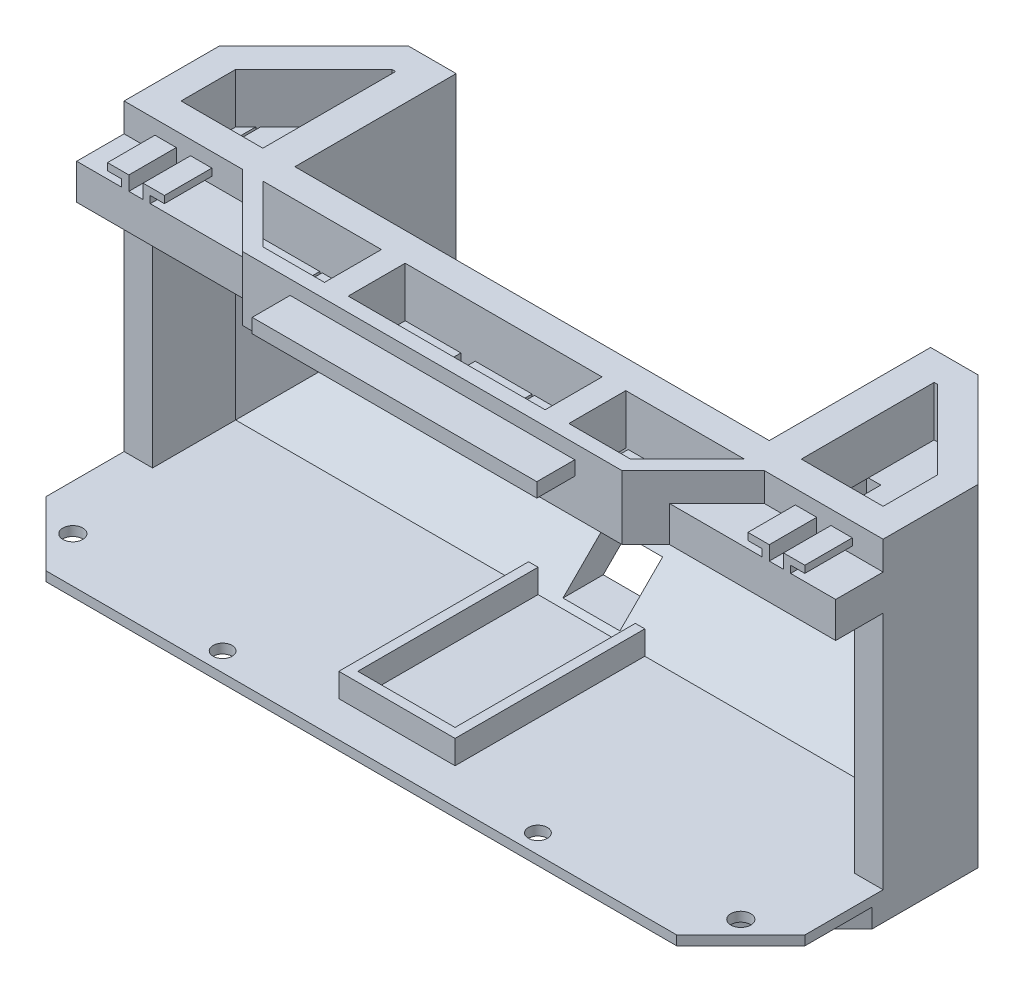
from build123d import *

# Parameters (mm, degrees)
BOSS_EXTRUDE1_DEPTH     = 70
CUT_EXTRUDE1_DEPTH      = 78.462449275
CUT_EXTRUDE1_DEPTH_BACK = 83.537550725
SHELL1_T                = -6
BOSS_EXTRUDE2_DEPTH     = 6
BOSS_EXTRUDE3_DEPTH     = 2
CUT_EXTRUDE5_REACH      = 68
SKETCH7_R               = 2.1
SKETCH7_R_2             = 2
BOSS_EXTRUDE4_DEPTH     = 10
CUT_EXTRUDE6_REACH      = 72
SKETCH9_W               = 41.514718626
SKETCH9_H               = 12
CUT_EXTRUDE7_DEPTH      = 37.591883099
SKETCH11_W              = 60
SKETCH11_H              = 3
BOSS_EXTRUDE5_DEPTH     = 8
SKETCH12_W              = 100
SKETCH12_H              = 34
CUT_EXTRUDE8_DEPTH      = 50
BOSS_EXTRUDE8_DEPTH     = 7
SKETCH14_W              = 100
SKETCH14_H              = 3
BOSS_EXTRUDE9_DEPTH     = 10
SKETCH15_W              = 100
SKETCH15_H              = 2
BOSS_EXTRUDE10_DEPTH    = 3
SKETCH16_W              = 20.5
SKETCH16_H              = 2
BOSS_EXTRUDE11_DEPTH    = 5
BOSS_EXTRUDE12_DEPTH    = 3
SKETCH18_W              = 41.514718626
SKETCH18_H              = 12
BOSS_EXTRUDE13_DEPTH    = 10.5
SKETCH19_W              = 0.5
SKETCH19_H              = 12
CUT_EXTRUDE10_DEPTH     = 3
SKETCH21_W              = 3
SKETCH21_H              = 12
CUT_EXTRUDE11_DEPTH     = 3
BOSS_EXTRUDE15_REACH    = 45
SKETCH23_W              = 3.757359313
SKETCH23_H              = 28
BOSS_EXTRUDE16_START    = -52.537551
BOSS_EXTRUDE16_DEPTH    = 100
SKETCH24_R              = 5
CUT_EXTRUDE12_DEPTH     = 3
CUT_EXTRUDE13_START     = -56.29491
CUT_EXTRUDE13_DEPTH     = 107.514719
BOSS_EXTRUDE17_DEPTH    = 7.5
SKETCH28_R              = 1.95
CUT_EXTRUDE14_DEPTH     = 5.485281


with BuildPart() as part:
    # Sketch2 → Boss-Extrude1 (new body)
    with BuildSketch(Plane(origin=(0, 0, 0), x_dir=(1, 0, 0), z_dir=(0, 1, 0))):
        Polygon((-62.537550725, 36.591883099), (57.462449275, 36.591883099), (77.462449275, 16.591883099), (77.462449275, -3.408116901), (52.462449275, -3.408116901), (37.462449275, -18.408116901), (-42.537550725, -18.408116901), (-57.537550725, -3.408116901), (-82.537550725, -3.408116901), (-82.537550725, 16.591883099), align=None)
    extrude(amount=BOSS_EXTRUDE1_DEPTH)

    # Sketch3 → Cut-Extrude1 (cut, two sides)
    with BuildSketch(Plane(origin=(0, 0, 0), x_dir=(0, 0, -1), z_dir=(1, 0, 0))) as cut_extrude1_sk:
        Polygon((16.591883099, 0), (36.591883099, 20), (36.591883099, 0), align=None)
    extrude(amount=CUT_EXTRUDE1_DEPTH, mode=Mode.SUBTRACT)
    extrude(cut_extrude1_sk.sketch, amount=-CUT_EXTRUDE1_DEPTH_BACK, mode=Mode.SUBTRACT)

    # Shell1
    shell1_openings = [part.faces().sort_by_distance(p)[0] for p in [
        (64.962449275, 35, 3.408116901),
        (44.962449275, 35, 10.908116901),
        (-2.537550725, 35, 18.408116901),
        (-50.037550725, 35, 10.908116901),
        (-70.037550725, 35, 3.408116901),
    ]]
    offset(amount=SHELL1_T, openings=shell1_openings, kind=Kind.INTERSECTION)

    # Sketch5 → Boss-Extrude2 (add)
    with BuildSketch(Plane.XZ):
        Polygon((77.462449275, -16.591883099), (-82.537550725, -16.591883099), (-82.537550725, 5.730447371), (-64.859881195, 23.408116901), (59.784779745, 23.408116901), (77.462449275, 5.730447371), align=None)
    extrude(amount=-BOSS_EXTRUDE2_DEPTH)

    # Sketch6 → Boss-Extrude3 (add)
    with BuildSketch(Plane(origin=(0, 6, 0), x_dir=(1, 0, 0), z_dir=(0, 1, 0))):
        Polygon((-82.537550725, -5.730447371), (-82.537550725, -19.872582995), (-69.002016819, -33.408116901), (63.926915369, -33.408116901), (77.462449275, -19.872582995), (77.462449275, -5.730447371), align=None)
    extrude(amount=-BOSS_EXTRUDE3_DEPTH)

    # Sketch7 → Cut-Extrude5 (cut, up to next)
    with BuildSketch(Plane.XZ.offset(-4), mode=Mode.PRIVATE) as cut_extrude5_sk1:
        with Locations((67.866255197, 23.811922823)):
            Circle(SKETCH7_R)
    cut_extrude5_tool1 = extrude(cut_extrude5_sk1.sketch, amount=-CUT_EXTRUDE5_REACH, mode=Mode.PRIVATE) & part.part
    add(cut_extrude5_tool1.solids().sort_by_distance((67.866255, 4, 23.811923))[0], mode=Mode.SUBTRACT)
    # Sketch7 → Cut-Extrude5 (cut, up to next)
    with BuildSketch(Plane.XZ.offset(-4), mode=Mode.PRIVATE) as cut_extrude5_sk2:
        with Locations((30.694682322, 29.408116901)):
            Circle(SKETCH7_R_2)
    cut_extrude5_tool2 = extrude(cut_extrude5_sk2.sketch, amount=-CUT_EXTRUDE5_REACH, mode=Mode.PRIVATE) & part.part
    add(cut_extrude5_tool2.solids().sort_by_distance((30.694682, 4, 29.408117))[0], mode=Mode.SUBTRACT)
    # Sketch7 → Cut-Extrude5 (cut, up to next)
    with BuildSketch(Plane.XZ.offset(-4), mode=Mode.PRIVATE) as cut_extrude5_sk3:
        with Locations((-72.941356647, 23.811922823)):
            Circle(SKETCH7_R)
    cut_extrude5_tool3 = extrude(cut_extrude5_sk3.sketch, amount=-CUT_EXTRUDE5_REACH, mode=Mode.PRIVATE) & part.part
    add(cut_extrude5_tool3.solids().sort_by_distance((-72.941357, 4, 23.811923))[0], mode=Mode.SUBTRACT)
    # Sketch7 → Cut-Extrude5 (cut, up to next)
    with BuildSketch(Plane.XZ.offset(-4), mode=Mode.PRIVATE) as cut_extrude5_sk4:
        with Locations((-35.769783772, 29.408116901)):
            Circle(SKETCH7_R_2)
    cut_extrude5_tool4 = extrude(cut_extrude5_sk4.sketch, amount=-CUT_EXTRUDE5_REACH, mode=Mode.PRIVATE) & part.part
    add(cut_extrude5_tool4.solids().sort_by_distance((-35.769784, 4, 29.408117))[0], mode=Mode.SUBTRACT)

    # Sketch8 → Boss-Extrude4 (add)
    with BuildSketch(Plane.XY.offset(3.408116901)):
        Polygon((-73.037550725, 64), (-73.037550725, 65.5), (-76.037550725, 65.5), (-76.037550725, 67), (-71.537550725, 67), (-71.537550725, 64), align=None)
        Polygon((-68.537550725, 67), (-68.537550725, 64), (-67.037550725, 64), (-67.037550725, 65.5), (-64.037550725, 65.5), (-64.037550725, 67), align=None)
        Polygon((58.962449275, 67), (63.462449275, 67), (63.462449275, 64), (61.962449275, 64), (61.962449275, 65.5), (58.962449275, 65.5), align=None)
        Polygon((66.462449275, 67), (66.462449275, 64), (67.962449275, 64), (67.962449275, 65.5), (70.962449275, 65.5), (70.962449275, 67), align=None)
    extrude(amount=BOSS_EXTRUDE4_DEPTH)

    # Sketch9 → Cut-Extrude6 (cut, up to next)
    with BuildSketch(Plane(origin=(0, 70, 0), x_dir=(1, 0, 0), z_dir=(0, 1, 0)), mode=Mode.PRIVATE) as cut_extrude6_sk1:
        Polygon((-76.537550725, 14.106601725), (-60.052269351, 30.591883099), (-59.294910038, 30.591883099), (-59.294910038, 2.591883099), (-76.537550725, 2.591883099), align=None)
    cut_extrude6_tool1 = extrude(cut_extrude6_sk1.sketch, amount=-CUT_EXTRUDE6_REACH, mode=Mode.PRIVATE) & part.part
    add(cut_extrude6_tool1.solids().sort_by_distance((-66.691715, 70, -13.260586))[0], mode=Mode.SUBTRACT)
    # Sketch9 → Cut-Extrude6 (cut, up to next)
    with BuildSketch(Plane(origin=(0, 70, 0), x_dir=(1, 0, 0), z_dir=(0, 1, 0)), mode=Mode.PRIVATE) as cut_extrude6_sk2:
        Polygon((-53.294910038, -3.408116901), (-41.294910038, -15.408116901), (-28.294910038, -15.408116901), (-28.294910038, -3.408116901), align=None)
    cut_extrude6_tool2 = extrude(cut_extrude6_sk2.sketch, amount=-CUT_EXTRUDE6_REACH, mode=Mode.PRIVATE) & part.part
    add(cut_extrude6_tool2.solids().sort_by_distance((-38.1107, 70, 8.776538))[0], mode=Mode.SUBTRACT)
    # Sketch9 → Cut-Extrude6 (cut, up to next)
    with BuildSketch(Plane(origin=(0, 70, 0), x_dir=(1, 0, 0), z_dir=(0, 1, 0)), mode=Mode.PRIVATE) as cut_extrude6_sk3:
        with Locations((-2.537550725, -9.408116901)):
            Rectangle(SKETCH9_W, SKETCH9_H)
    cut_extrude6_tool3 = extrude(cut_extrude6_sk3.sketch, amount=-CUT_EXTRUDE6_REACH, mode=Mode.PRIVATE) & part.part
    add(cut_extrude6_tool3.solids().sort_by_distance((-2.537551, 70, 9.408117))[0], mode=Mode.SUBTRACT)
    # Sketch9 → Cut-Extrude6 (cut, up to next)
    with BuildSketch(Plane(origin=(0, 70, 0), x_dir=(1, 0, 0), z_dir=(0, 1, 0)), mode=Mode.PRIVATE) as cut_extrude6_sk4:
        Polygon((23.219808588, -15.408116901), (23.219808588, -3.408116901), (48.219808588, -3.408116901), (36.219808588, -15.408116901), align=None)
    cut_extrude6_tool4 = extrude(cut_extrude6_sk4.sketch, amount=-CUT_EXTRUDE6_REACH, mode=Mode.PRIVATE) & part.part
    add(cut_extrude6_tool4.solids().sort_by_distance((33.035598, 70, 8.776538))[0], mode=Mode.SUBTRACT)
    # Sketch9 → Cut-Extrude6 (cut, up to next)
    with BuildSketch(Plane(origin=(0, 70, 0), x_dir=(1, 0, 0), z_dir=(0, 1, 0)), mode=Mode.PRIVATE) as cut_extrude6_sk5:
        Polygon((54.219808588, 2.591883099), (71.462449275, 2.591883099), (71.462449275, 14.106601725), (54.977167901, 30.591883099), (54.219808588, 30.591883099), align=None)
    cut_extrude6_tool5 = extrude(cut_extrude6_sk5.sketch, amount=-CUT_EXTRUDE6_REACH, mode=Mode.PRIVATE) & part.part
    add(cut_extrude6_tool5.solids().sort_by_distance((61.616614, 70, -13.260586))[0], mode=Mode.SUBTRACT)

    # Sketch10 → Cut-Extrude7 (cut, through all)
    with BuildSketch(Plane.XY):
        Polygon((-8.537550725, 7), (-8.537550725, 16), (3.462449275, 16), (3.462449275, 7), (-2.537550725, 7), align=None)
    extrude(amount=-CUT_EXTRUDE7_DEPTH, mode=Mode.SUBTRACT)

    # Sketch11 → Boss-Extrude5 (add)
    with BuildSketch(Plane.XY.offset(18.408116901)):
        with Locations((-2.537550725, 65.5)):
            Rectangle(SKETCH11_W, SKETCH11_H)
    extrude(amount=BOSS_EXTRUDE5_DEPTH)

    # Sketch12 → Cut-Extrude8 (cut)
    with BuildSketch(Plane(origin=(0, 70, 0), x_dir=(1, 0, 0), z_dir=(0, 1, 0))):
        with Locations((-2.537550725, 19.591883099)):
            Rectangle(SKETCH12_W, SKETCH12_H)
    extrude(amount=-CUT_EXTRUDE8_DEPTH, mode=Mode.SUBTRACT)

    # Sketch13 → Boss-Extrude8 (add)
    with BuildSketch(Plane(origin=(0, 20, 0), x_dir=(1, 0, 0), z_dir=(0, 1, 0))):
        Polygon((-52.537550725, 28.106601725), (43.977167901, 28.106601725), (51.219808588, 28.106601725), (51.219808588, 30.591883099), (47.462449275, 30.591883099), (-49.052269351, 30.591883099), (-56.294910038, 30.591883099), (-56.294910038, 28.106601725), align=None)
    extrude(amount=BOSS_EXTRUDE8_DEPTH)

    # Sketch14 → Boss-Extrude9 (add)
    with BuildSketch(Plane(origin=(0, 20, 0), x_dir=(1, 0, 0), z_dir=(0, 1, 0))):
        with Locations((-2.537550725, 35.091883099)):
            Rectangle(SKETCH14_W, SKETCH14_H)
    extrude(amount=BOSS_EXTRUDE9_DEPTH)

    # Sketch15 → Boss-Extrude10 (add)
    with BuildSketch(Plane(origin=(0, 0, -2.591883099), x_dir=(-1, 0, 0), z_dir=(0, 0, -1))):
        with Locations((2.537550725, 65)):
            Rectangle(SKETCH15_W, SKETCH15_H)
    extrude(amount=BOSS_EXTRUDE10_DEPTH)

    # Sketch16 → Boss-Extrude11 (add)
    with BuildSketch(Plane(origin=(0, 6, 0), x_dir=(1, 0, 0), z_dir=(0, 1, 0))):
        Polygon((-12.787550725, -25.893398275), (-12.787550725, -23.893398275), (-12.787550725, 14.106601725), (-14.787550725, 14.106601725), (-14.787550725, -25.893398275), align=None)
        with Locations((-2.537550725, -24.893398275)):
            Rectangle(SKETCH16_W, SKETCH16_H)
        Polygon((7.712449275, 14.106601725), (7.712449275, -23.893398275), (7.712449275, -25.893398275), (9.712449275, -25.893398275), (9.712449275, 14.106601725), align=None)
    extrude(amount=BOSS_EXTRUDE11_DEPTH)

    # Sketch17 → Boss-Extrude12 (add)
    with BuildSketch(Plane(origin=(0, 59.5, 0), x_dir=(1, 0, 0), z_dir=(0, 1, 0))):
        Polygon((-76.537550725, 14.106601725), (-60.052269351, 30.591883099), (-56.294910038, 30.591883099), (-56.294910038, -0.408116901), (-25.294910038, -0.408116901), (21.219808588, -0.408116901), (51.219808588, -0.408116901), (51.219808588, 30.591883099), (54.977167901, 30.591883099), (71.462449275, 14.106601725), (71.462449275, -0.408116901), (55.462449275, -0.408116901), (37.462449275, -18.408116901), (21.219808588, -18.408116901), (-25.294910038, -18.408116901), (-42.537550725, -18.408116901), (-60.537550725, -0.408116901), (-76.537550725, -0.408116901), align=None)
    extrude(amount=-BOSS_EXTRUDE12_DEPTH)

    # Sketch18 → Boss-Extrude13 (add)
    with BuildSketch(Plane(origin=(0, 59.5, 0), x_dir=(1, 0, 0), z_dir=(0, 1, 0))):
        Polygon((-56.294910038, 30.591883099), (-59.294910038, 30.591883099), (-59.294910038, 2.591883099), (-76.537550725, 2.591883099), (-76.537550725, -0.408116901), (-60.537550725, -0.408116901), (-42.537550725, -18.408116901), (37.462449275, -18.408116901), (55.462449275, -0.408116901), (71.462449275, -0.408116901), (71.462449275, 2.591883099), (54.219808588, 2.591883099), (54.219808588, 30.591883099), (51.219808588, 30.591883099), (51.219808588, -0.408116901), (-56.294910038, -0.408116901), align=None)
        Polygon((-53.294910038, -3.408116901), (-41.294910038, -15.408116901), (-28.294910038, -15.408116901), (-28.294910038, -3.408116901), align=None, mode=Mode.SUBTRACT)
        with Locations((-2.537550725, -9.408116901)):
            Rectangle(SKETCH18_W, SKETCH18_H, mode=Mode.SUBTRACT)
        Polygon((23.219808588, -3.408116901), (23.219808588, -15.408116901), (36.219808588, -15.408116901), (48.219808588, -3.408116901), align=None, mode=Mode.SUBTRACT)
    extrude(amount=BOSS_EXTRUDE13_DEPTH)

    # Sketch19 → Cut-Extrude10 (cut)
    with BuildSketch(Plane(origin=(0, 59.5, 0), x_dir=(1, 0, 0), z_dir=(0, 1, 0))):
        with Locations((35.969808588, -9.408116901)):
            Rectangle(SKETCH19_W, SKETCH19_H)
        with Locations((-61.666230382, 10.727922068)):
            Rectangle(SKETCH19_W, SKETCH19_H)
        Polygon((-74.416230382, 16.227922068), (-74.416230382, 4.727922068), (-73.916230382, 4.727922068), (-73.916230382, 16.727922068), align=None)
        with Locations((-41.044910038, -9.408116901)):
            Rectangle(SKETCH19_W, SKETCH19_H)
        with Locations((-28.544910038, -9.408116901)):
            Rectangle(SKETCH19_W, SKETCH19_H)
        with Locations((-8.787550725, -9.408116901)):
            Rectangle(SKETCH19_W, SKETCH19_H)
        with Locations((3.712449275, -9.408116901)):
            Rectangle(SKETCH19_W, SKETCH19_H)
        with Locations((23.469808588, -9.408116901)):
            Rectangle(SKETCH19_W, SKETCH19_H)
        with Locations((56.591128931, 10.727922068)):
            Rectangle(SKETCH19_W, SKETCH19_H)
        Polygon((69.341128931, 16.227922068), (69.341128931, 4.727922068), (68.841128931, 4.727922068), (68.841128931, 16.727922068), align=None)
    extrude(amount=-CUT_EXTRUDE10_DEPTH, mode=Mode.SUBTRACT)

    # Sketch21 → Cut-Extrude11 (cut)
    with BuildSketch(Plane(origin=(0, 56.5, 0), x_dir=(-1, 0, 0), z_dir=(0, -1, 0))):
        with Locations((27.294910038, -9.408116901)):
            Rectangle(SKETCH21_W, SKETCH21_H)
        with Locations((60.416230382, 10.727922068)):
            Rectangle(SKETCH21_W, SKETCH21_H)
        with Locations((10.037550725, -9.408116901)):
            Rectangle(SKETCH21_W, SKETCH21_H)
        with Locations((-22.219808588, -9.408116901)):
            Rectangle(SKETCH21_W, SKETCH21_H)
        with Locations((-55.341128931, 10.727922068)):
            Rectangle(SKETCH21_W, SKETCH21_H)
    extrude(amount=-CUT_EXTRUDE11_DEPTH, mode=Mode.SUBTRACT)

    # Sketch23 → Boss-Extrude15 (add, up to next)
    with BuildSketch(Plane(origin=(0, 27, 0), x_dir=(1, 0, 0), z_dir=(0, 1, 0)), mode=Mode.PRIVATE) as boss_extrude15_sk1:
        with Locations((-54.416230382, 16.591883099)):
            Rectangle(SKETCH23_W, SKETCH23_H)
    boss_extrude15_tool1 = extrude(boss_extrude15_sk1.sketch, amount=BOSS_EXTRUDE15_REACH, mode=Mode.PRIVATE) - part.part
    add(boss_extrude15_tool1.solids().sort_by_distance((-54.41623, 27, -16.591883))[0])
    # Sketch23 → Boss-Extrude15 (add, up to next)
    with BuildSketch(Plane(origin=(0, 27, 0), x_dir=(1, 0, 0), z_dir=(0, 1, 0)), mode=Mode.PRIVATE) as boss_extrude15_sk2:
        with Locations((49.341128932, 16.591883099)):
            Rectangle(SKETCH23_W, SKETCH23_H)
    boss_extrude15_tool2 = extrude(boss_extrude15_sk2.sketch, amount=BOSS_EXTRUDE15_REACH, mode=Mode.PRIVATE) - part.part
    add(boss_extrude15_tool2.solids().sort_by_distance((49.341129, 27, -16.591883))[0])

    # Sketch22 → Boss-Extrude16 (add)
    with BuildSketch(Plane(origin=(0, 0, 0), x_dir=(0, 0, -1), z_dir=(1, 0, 0)).offset(BOSS_EXTRUDE16_START)):
        Polygon((5.591883099, 66), (30.591883099, 30), (30.591883099, 27), (28.106601725, 27), (28.127773202, 28.288812572), (3.127773202, 64.288812572), align=None)
    extrude(amount=BOSS_EXTRUDE16_DEPTH)

    # Sketch24 → Cut-Extrude12 (cut)
    with BuildSketch(Plane(origin=(0, 3.815537533, -48.77553759), x_dir=(-1, 0, 0), z_dir=(0, 0.570395809, -0.821369966))):
        with Locations((2.537550725, 57.708225362)):
            Circle(SKETCH24_R)
    extrude(amount=-CUT_EXTRUDE12_DEPTH, mode=Mode.SUBTRACT)

    # Sketch26 → Cut-Extrude13 (cut)
    with BuildSketch(Plane(origin=(0, 0, 0), x_dir=(0, 0, -1), z_dir=(1, 0, 0)).offset(CUT_EXTRUDE13_START)):
        Polygon((28.106601725, 27), (28.127773202, 28.288812572), (3.328337488, 64), (2.591883099, 64), (2.591883099, 27), align=None)
    extrude(amount=CUT_EXTRUDE13_DEPTH, mode=Mode.SUBTRACT)

    # Sketch27 → Boss-Extrude17 (add)
    with BuildSketch(Plane.XZ.offset(-64)):
        Polygon((-82.537550725, 0.408116901), (-56.294910038, 0.408116901), (-47.537550725, 9.165476214), (-47.537550725, 13.408116901), (-82.537550725, 13.408116901), align=None)
        Polygon((77.462449275, 0.408116901), (77.462449275, 13.408116901), (42.462449275, 13.408116901), (42.462449275, 9.165476214), (51.219808588, 0.408116901), align=None)
    extrude(amount=BOSS_EXTRUDE17_DEPTH)

    # Sketch28 → Cut-Extrude14 (cut)
    with BuildSketch(Plane.XY.offset(-28.106601725)):
        with Locations((17.462449275, 24.144406286)):
            Circle(SKETCH28_R)
        with Locations((-22.537550725, 24.144406286)):
            Circle(SKETCH28_R)
    extrude(amount=-CUT_EXTRUDE14_DEPTH, mode=Mode.SUBTRACT)


solid = part.part
